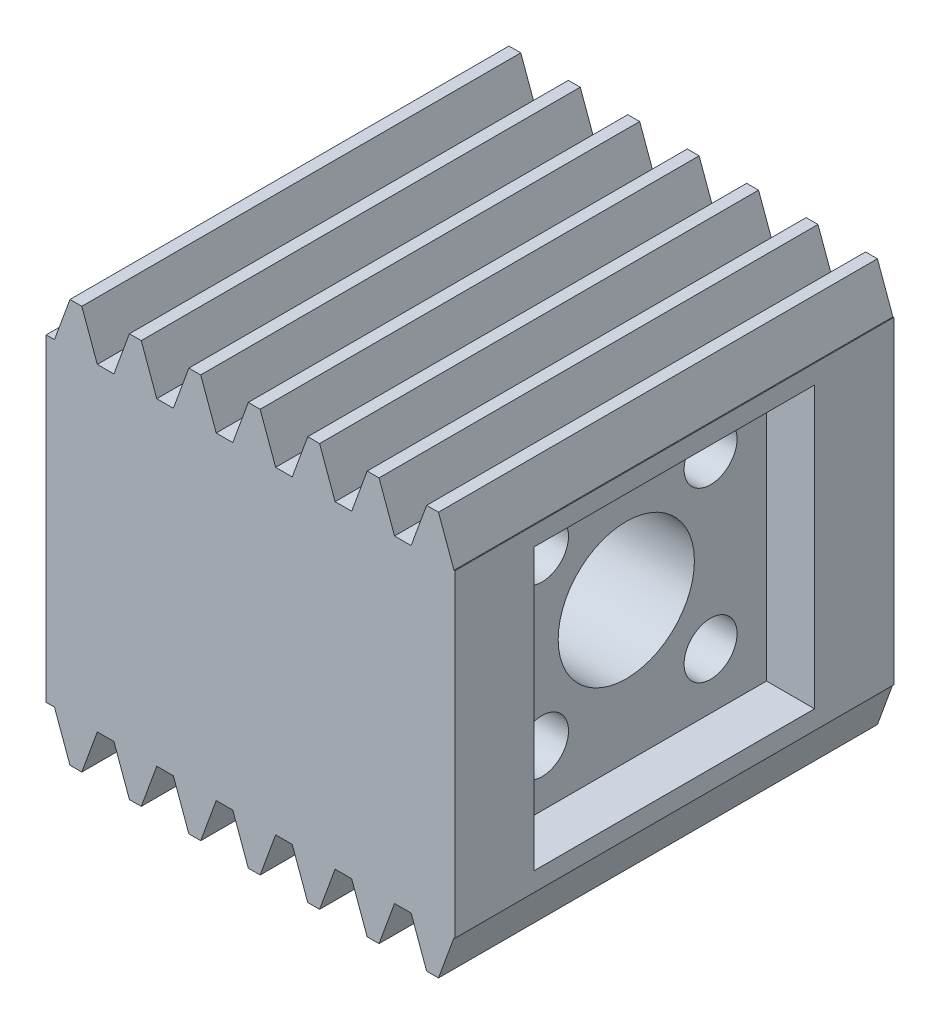
from build123d import *

# Parameters (mm, degrees)
BLANKSKE_W           = 27
BLANKSKE_H           = 13.325
BLANK_DEPTH          = 29
TOOTHCUTSIM_DEPTH    = 42.803775248
TEETHCUTS_COUNT      = 8
TEETHCUTS_PITCH      = 3.926990813
CUT_EXTRUDE1_DEPTH   = 6.75
SKETCH3_R            = 5.25
CUT_EXTRUDE2_DEPTH   = 10.25
SKETCH4_R            = 4.5
CUT_EXTRUDE3_DEPTH   = 37.16013862
SKETCH5_R            = 2.5
CUT_EXTRUDE4_DEPTH   = 3.175
SKETCH6_R            = 1.75
CUT_EXTRUDE5_DEPTH   = 40.826953813
MIRROR1_COPY_1_DEPTH = 42.803775248
MIRROR1_COPY_2_DEPTH = 42.803775248
MIRROR1_COPY_3_DEPTH = 42.803775248
MIRROR1_COPY_4_DEPTH = 42.803775248
MIRROR1_COPY_5_DEPTH = 42.803775248
MIRROR1_COPY_6_DEPTH = 42.803775248
MIRROR1_COPY_7_DEPTH = 42.803775248
SKETCH9_W            = 18.526
SKETCH9_H            = 18.526
CUT_EXTRUDE6_DEPTH   = 3.175


with BuildPart() as part:
    # BlankSke → Blank (new body)
    with BuildSketch(Plane.XY):
        with Locations((13.5, 6.6625)):
            Rectangle(BLANKSKE_W, BLANKSKE_H)
    blank = extrude(amount=-BLANK_DEPTH)

    # TooCutSkeSim → ToothCutSim (cut, through all)
    with BuildSketch(Plane.XY):
        Polygon((0.548044212, 10.5125), (-0.548044212, 10.5125), (-1.58095534, 13.3504), (1.58095534, 13.3504), align=None)
    toothcutsim = extrude(amount=-TOOTHCUTSIM_DEPTH, mode=Mode.SUBTRACT)

    # TeethCuts: ToothCutSim ×8
    with Locations(*[(i * TEETHCUTS_PITCH, 0, 0) for i in range(1, TEETHCUTS_COUNT)]):
        add(toothcutsim, mode=Mode.SUBTRACT)

    # Sketch2 → Cut-Extrude1 (cut)
    with BuildSketch(Plane.ZY):
        with BuildLine():
            Line((-7.445049185, 8.763), (-21.554950815, 8.763))
            ThreePointArc((-21.554950815, 8.763), (-24.647184256, 4.857689952), (-25.75, 0))
            Line((-25.75, 0), (-3.25, 0))
            ThreePointArc((-3.25, 0), (-4.352815744, 4.857689952), (-7.445049185, 8.763))
        make_face()
    cut_extrude1 = extrude(amount=-CUT_EXTRUDE1_DEPTH, mode=Mode.SUBTRACT)

    # Sketch3 → Cut-Extrude2 (cut)
    with BuildSketch(Plane.ZY.offset(-6.75)):
        with Locations((-14.5, 0)):
            Circle(SKETCH3_R)
    cut_extrude2 = extrude(amount=-CUT_EXTRUDE2_DEPTH, mode=Mode.SUBTRACT)

    # Sketch4 → Cut-Extrude3 (cut, symmetric)
    with BuildSketch(Plane.ZY.offset(-17)):
        with Locations((-14.5, 0)):
            Circle(SKETCH4_R)
    cut_extrude3 = extrude(amount=CUT_EXTRUDE3_DEPTH, both=True, mode=Mode.SUBTRACT)

    # Sketch5 → Cut-Extrude4 (cut)
    with BuildSketch(Plane(origin=(27, 0, 0), x_dir=(0, 0, -1), z_dir=(1, 0, 0))):
        with Locations((8.932241205, 5.567758795)):
            Circle(SKETCH5_R)
        with Locations((20.067758795, 5.567758795)):
            Circle(SKETCH5_R)
    cut_extrude4 = extrude(amount=-CUT_EXTRUDE4_DEPTH, mode=Mode.SUBTRACT)

    # Sketch6 → Cut-Extrude5 (cut, through all)
    with BuildSketch(Plane(origin=(23.825, 0, 0), x_dir=(0, 0, -1), z_dir=(1, 0, 0))):
        with Locations((20.067758795, 5.567758795)):
            Circle(SKETCH6_R)
        with Locations((8.932241205, 5.567758795)):
            Circle(SKETCH6_R)
    cut_extrude5 = extrude(amount=-CUT_EXTRUDE5_DEPTH, mode=Mode.SUBTRACT)

    # Mirror1: Blank, ToothCutSim, Cut-Extrude1, Cut-Extrude2, Cut-Extrude3, Cut-Extrude4, Cut-Extrude5 across plane
    add(blank.mirror(Plane(origin=(0, 0, -29), x_dir=(0, 0, 1), z_dir=(0, -1, 0))))
    add(toothcutsim.mirror(Plane(origin=(0, 0, -29), x_dir=(0, 0, 1), z_dir=(0, -1, 0))), mode=Mode.SUBTRACT)
    add(cut_extrude1.mirror(Plane(origin=(0, 0, -29), x_dir=(0, 0, 1), z_dir=(0, -1, 0))), mode=Mode.SUBTRACT)
    add(cut_extrude2.mirror(Plane(origin=(0, 0, -29), x_dir=(0, 0, 1), z_dir=(0, -1, 0))), mode=Mode.SUBTRACT)
    add(cut_extrude3.mirror(Plane(origin=(0, 0, -29), x_dir=(0, 0, 1), z_dir=(0, -1, 0))), mode=Mode.SUBTRACT)
    add(cut_extrude4.mirror(Plane(origin=(0, 0, -29), x_dir=(0, 0, 1), z_dir=(0, -1, 0))), mode=Mode.SUBTRACT)
    add(cut_extrude5.mirror(Plane(origin=(0, 0, -29), x_dir=(0, 0, 1), z_dir=(0, -1, 0))), mode=Mode.SUBTRACT)

    # Mirror1 copy 1 sketch → Mirror1 copy 1 (cut, through all)
    with BuildSketch(Plane(origin=(3.926990813, 0, 0), x_dir=(1, 0, 0), z_dir=(0, 0, 1))):
        Polygon((0.548044212, -10.5125), (-0.548044212, -10.5125), (-1.58095534, -13.3504), (1.58095534, -13.3504), align=None)
    extrude(amount=-MIRROR1_COPY_1_DEPTH, mode=Mode.SUBTRACT)

    # Mirror1 copy 2 sketch → Mirror1 copy 2 (cut, through all)
    with BuildSketch(Plane(origin=(7.853981625, 0, 0), x_dir=(1, 0, 0), z_dir=(0, 0, 1))):
        Polygon((0.548044212, -10.5125), (-0.548044212, -10.5125), (-1.58095534, -13.3504), (1.58095534, -13.3504), align=None)
    extrude(amount=-MIRROR1_COPY_2_DEPTH, mode=Mode.SUBTRACT)

    # Mirror1 copy 3 sketch → Mirror1 copy 3 (cut, through all)
    with BuildSketch(Plane(origin=(11.780972438, 0, 0), x_dir=(1, 0, 0), z_dir=(0, 0, 1))):
        Polygon((0.548044212, -10.5125), (-0.548044212, -10.5125), (-1.58095534, -13.3504), (1.58095534, -13.3504), align=None)
    extrude(amount=-MIRROR1_COPY_3_DEPTH, mode=Mode.SUBTRACT)

    # Mirror1 copy 4 sketch → Mirror1 copy 4 (cut, through all)
    with BuildSketch(Plane(origin=(15.70796325, 0, 0), x_dir=(1, 0, 0), z_dir=(0, 0, 1))):
        Polygon((0.548044212, -10.5125), (-0.548044212, -10.5125), (-1.58095534, -13.3504), (1.58095534, -13.3504), align=None)
    extrude(amount=-MIRROR1_COPY_4_DEPTH, mode=Mode.SUBTRACT)

    # Mirror1 copy 5 sketch → Mirror1 copy 5 (cut, through all)
    with BuildSketch(Plane(origin=(19.634954063, 0, 0), x_dir=(1, 0, 0), z_dir=(0, 0, 1))):
        Polygon((0.548044212, -10.5125), (-0.548044212, -10.5125), (-1.58095534, -13.3504), (1.58095534, -13.3504), align=None)
    extrude(amount=-MIRROR1_COPY_5_DEPTH, mode=Mode.SUBTRACT)

    # Mirror1 copy 6 sketch → Mirror1 copy 6 (cut, through all)
    with BuildSketch(Plane(origin=(23.561944875, 0, 0), x_dir=(1, 0, 0), z_dir=(0, 0, 1))):
        Polygon((0.548044212, -10.5125), (-0.548044212, -10.5125), (-1.58095534, -13.3504), (1.58095534, -13.3504), align=None)
    extrude(amount=-MIRROR1_COPY_6_DEPTH, mode=Mode.SUBTRACT)

    # Mirror1 copy 7 sketch → Mirror1 copy 7 (cut, through all)
    with BuildSketch(Plane(origin=(27.488935688, 0, 0), x_dir=(1, 0, 0), z_dir=(0, 0, 1))):
        Polygon((0.548044212, -10.5125), (-0.548044212, -10.5125), (-1.58095534, -13.3504), (1.58095534, -13.3504), align=None)
    extrude(amount=-MIRROR1_COPY_7_DEPTH, mode=Mode.SUBTRACT)

    # Sketch9 → Cut-Extrude6 (cut)
    with BuildSketch(Plane(origin=(27, 0, 0), x_dir=(0, 0, -1), z_dir=(1, 0, 0))):
        with Locations((14.5, 0)):
            Rectangle(SKETCH9_W, SKETCH9_H)
    extrude(amount=-CUT_EXTRUDE6_DEPTH, mode=Mode.SUBTRACT)


solid = part.part
